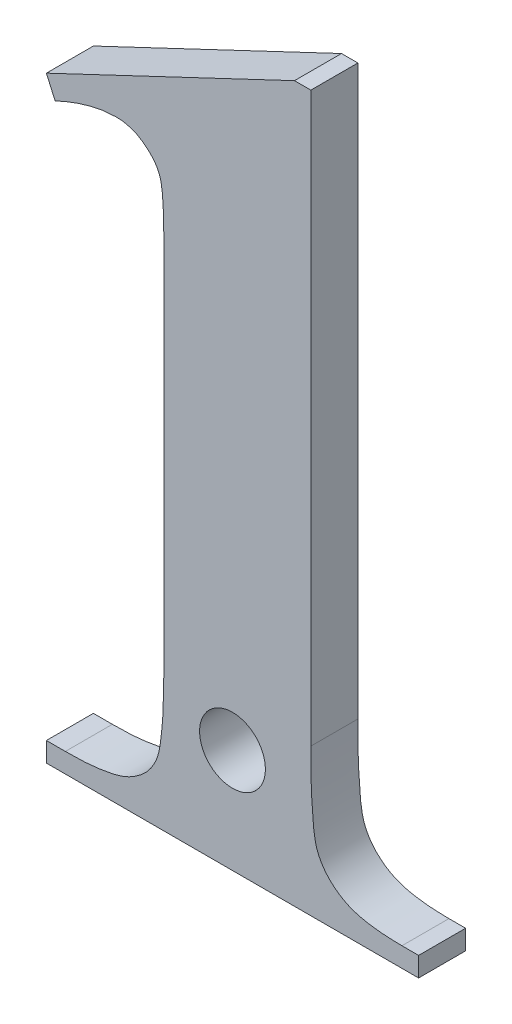
from build123d import *

# Parameters (mm, degrees)
BOSS_EXTRU_1_DEPTH     = 2
D_GAGEMENT_M1_61_D     = 2.8
D_GAGEMENT_M1_61_DEPTH = 50


with BuildPart() as part:
    # Esquisse1 → Boss.-Extru.1 (new body)
    with BuildSketch(Plane.XY):
        with BuildLine():
            Line((14.583333333, 30.416666667), (14.583333333, 6.25))
            add(Edge.make_bspline(
                [(14.583333333, 6.25), (14.585749256, 6.024308084), (14.59037205, 5.592453393), (14.593107367, 4.978161783), (14.611405028, 4.426616136), (14.646981306, 3.940846138), (14.677395441, 3.517336674), (14.712944408, 3.158101024), (14.76514446, 2.864876435), (14.838888581, 2.560406748), (14.984413764, 2.239748818), (15.214960792, 1.893733621), (15.519630906, 1.587915439), (15.89450585, 1.310922857), (16.371078344, 1.084888289), (16.965143818, 0.937715107), (17.673153617, 0.850195969), (18.183296053, 0.839221876), (18.45703125, 0.833333333)],
                knots=[0, 0, 0, 0, 0.000677115, 0.001295638, 0.001842862, 0.002332227, 0.002756654, 0.003116852, 0.003414414, 0.003649692, 0.00405491, 0.004462994, 0.00489115, 0.005343002, 0.005855509, 0.006461922, 0.00717093, 0.007991888, 0.007991888, 0.007991888, 0.007991888], degree=3))
            Line((18.45703125, 0.833333333), (19.166666667, 0.833333333))
            Line((19.166666667, 0.833333333), (19.166666667, 0))
            Line((19.166666667, 0), (3.333333333, 0))
            Line((3.333333333, 0), (3.333333333, 0.833333333))
            Line((3.333333333, 0.833333333), (4.140625, 0.833333333))
            add(Edge.make_bspline(
                [(4.140625, 0.833333333), (4.442698328, 0.835687663), (5.002899694, 0.840053817), (5.770530007, 0.936228913), (6.406632939, 1.056476205), (6.907434423, 1.264218402), (7.299563384, 1.524264009), (7.623976899, 1.81310173), (7.8692092, 2.158416764), (8.028282693, 2.48159017), (8.121575873, 2.791758159), (8.177804506, 3.092907226), (8.218234515, 3.458964912), (8.267780142, 3.887964386), (8.298038135, 4.385502072), (8.315191657, 4.947815768), (8.328806999, 5.577198632), (8.331771102, 6.017787475), (8.333333333, 6.25)],
                knots=[0, 0, 0, 0, 0.000905323, 0.00167894, 0.002318719, 0.002841055, 0.003292486, 0.003725612, 0.00413582, 0.004555123, 0.004800195, 0.005105353, 0.005472773, 0.005904871, 0.006400732, 0.006967475, 0.007592611, 0.008289256, 0.008289256, 0.008289256, 0.008289256], degree=3))
            Line((8.333333333, 6.25), (8.333333333, 21.666666667))
            add(Edge.make_bspline(
                [(8.333333333, 21.666666667), (8.330801084, 21.95966099), (8.326278557, 22.482940639), (8.297258707, 23.178440933), (8.247847929, 23.693374102), (8.145609707, 24.145908108), (7.885508384, 24.565723563), (7.527134719, 24.875008937), (7.193015137, 25.095723854), (6.902051175, 25.199461425), (6.599395613, 25.279885687), (6.389469577, 25.284240422), (6.282552083, 25.286458333)],
                knots=[0, 0, 0, 0, 0.000879003, 0.001569874, 0.002087524, 0.002430172, 0.002952712, 0.003533418, 0.003840513, 0.004147609, 0.004455532, 0.00477514, 0.00477514, 0.00477514, 0.00477514], degree=3))
            add(Edge.make_bspline(
                [(6.282552083, 25.286458333), (6.095285486, 25.27628682), (5.699440202, 25.254786213), (5.079734294, 25.112739688), (4.404756441, 24.891410222), (3.945850809, 24.689536321), (3.704427083, 24.583333333)],
                knots=[0, 0, 0, 0, 0.000561747, 0.001187425, 0.001899773, 0.002690541, 0.002690541, 0.002690541, 0.002690541], degree=3))
            Line((3.704427083, 24.583333333), (3.333333333, 25.416666667))
            Line((3.333333333, 25.416666667), (13.88671875, 30.416666667))
            Line((13.88671875, 30.416666667), (14.583333333, 30.416666667))
        make_face()
    extrude(amount=BOSS_EXTRU_1_DEPTH)

    # Dégagement M1.61
    with Locations(Plane.XY.offset(2)):
        with Locations((11.25, 4.431023469)):
            Hole(D_GAGEMENT_M1_61_D / 2, depth=D_GAGEMENT_M1_61_DEPTH)


solid = part.part
